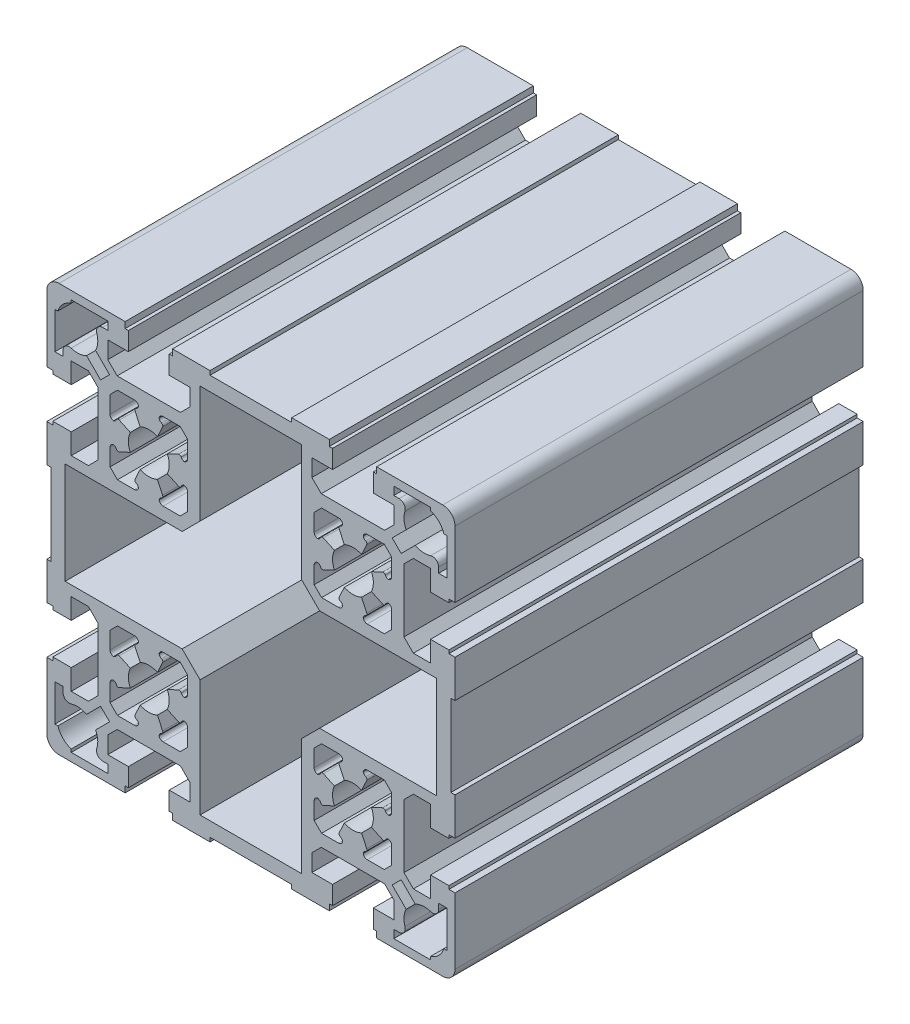
from build123d import *

# Parameters (mm, degrees)
BASE_EXTRUDE_DEPTH = 100


with BuildPart() as part:
    # Sketch1 → Base-Extrude (new body)
    with BuildSketch(Plane.XY):
        with BuildLine():
            Line((-17.25, -37.5), (-14.95, -39.8))
            Line((-14.95, -39.8), (-14.95, -44))
            Line((-14.95, -44), (-20, -44))
            Line((-20, -44), (-20, -48.5))
            Line((-20, -48.5), (-19.2, -48.5))
            Line((-19.2, -48.5), (-19.2, -50))
            Line((-19.2, -50), (-10, -50))
            Line((-10, -50), (-10, -49))
            Line((-10, -49), (10, -49))
            Line((10, -49), (10, -50))
            Line((10, -50), (19.2, -50))
            Line((19.2, -50), (19.2, -48.5))
            Line((19.2, -48.5), (20, -48.5))
            Line((20, -48.5), (20, -44))
            Line((20, -44), (14.95, -44))
            Line((14.95, -44), (14.95, -39.8))
            Line((14.95, -39.8), (17.25, -37.5))
            Line((17.25, -37.5), (32.75, -37.5))
            Line((32.75, -37.5), (35.05, -39.8))
            Line((35.05, -39.8), (35.05, -44))
            Line((35.05, -44), (30, -44))
            Line((30, -44), (30, -48.5))
            Line((30, -48.5), (30.8, -48.5))
            Line((30.8, -48.5), (30.8, -50))
            Line((30.8, -50), (47, -50))
            ThreePointArc((47, -50), (49.121320344, -49.121320344), (50, -47))
            Line((50, -47), (50, -30.8))
            Line((50, -30.8), (48.5, -30.8))
            Line((48.5, -30.8), (48.5, -30))
            Line((48.5, -30), (44, -30))
            Line((44, -30), (44, -35.05))
            Line((44, -35.05), (39.8, -35.05))
            Line((39.8, -35.05), (37.5, -32.75))
            Line((37.5, -32.75), (37.5, -17.25))
            Line((37.5, -17.25), (39.8, -14.95))
            Line((39.8, -14.95), (44, -14.95))
            Line((44, -14.95), (44, -20))
            Line((44, -20), (48.5, -20))
            Line((48.5, -20), (48.5, -19.2))
            Line((48.5, -19.2), (50, -19.2))
            Line((50, -19.2), (50, -10))
            Line((50, -10), (49, -10))
            Line((49, -10), (49, 10))
            Line((49, 10), (50, 10))
            Line((50, 10), (50, 19.2))
            Line((50, 19.2), (48.5, 19.2))
            Line((48.5, 19.2), (48.5, 20))
            Line((48.5, 20), (44, 20))
            Line((44, 20), (44, 14.95))
            Line((44, 14.95), (39.8, 14.95))
            Line((39.8, 14.95), (37.5, 17.25))
            Line((37.5, 17.25), (37.5, 32.75))
            Line((37.5, 32.75), (39.8, 35.05))
            Line((39.8, 35.05), (44, 35.05))
            Line((44, 35.05), (44, 30))
            Line((44, 30), (48.5, 30))
            Line((48.5, 30), (48.5, 30.8))
            Line((48.5, 30.8), (50, 30.8))
            Line((50, 30.8), (50, 47))
            ThreePointArc((50, 47), (49.121320344, 49.121320344), (47, 50))
            Line((47, 50), (30.8, 50))
            Line((30.8, 50), (30.8, 48.5))
            Line((30.8, 48.5), (30, 48.5))
            Line((30, 48.5), (30, 44))
            Line((30, 44), (35.05, 44))
            Line((35.05, 44), (35.05, 39.8))
            Line((35.05, 39.8), (32.75, 37.5))
            Line((32.75, 37.5), (17.25, 37.5))
            Line((17.25, 37.5), (14.95, 39.8))
            Line((14.95, 39.8), (14.95, 44))
            Line((14.95, 44), (20, 44))
            Line((20, 44), (20, 48.5))
            Line((20, 48.5), (19.2, 48.5))
            Line((19.2, 48.5), (19.2, 50))
            Line((19.2, 50), (10, 50))
            Line((10, 50), (10, 49))
            Line((10, 49), (-10, 49))
            Line((-10, 49), (-10, 50))
            Line((-10, 50), (-19.2, 50))
            Line((-19.2, 50), (-19.2, 48.5))
            Line((-19.2, 48.5), (-20, 48.5))
            Line((-20, 48.5), (-20, 44))
            Line((-20, 44), (-14.95, 44))
            Line((-14.95, 44), (-14.95, 39.8))
            Line((-14.95, 39.8), (-17.25, 37.5))
            Line((-17.25, 37.5), (-32.75, 37.5))
            Line((-32.75, 37.5), (-35.05, 39.8))
            Line((-35.05, 39.8), (-35.05, 44))
            Line((-35.05, 44), (-30, 44))
            Line((-30, 44), (-30, 48.5))
            Line((-30, 48.5), (-30.8, 48.5))
            Line((-30.8, 48.5), (-30.8, 50))
            Line((-30.8, 50), (-47, 50))
            ThreePointArc((-47, 50), (-49.121320344, 49.121320344), (-50, 47))
            Line((-50, 47), (-50, 30.8))
            Line((-50, 30.8), (-48.5, 30.8))
            Line((-48.5, 30.8), (-48.5, 30))
            Line((-48.5, 30), (-44, 30))
            Line((-44, 30), (-44, 35.05))
            Line((-44, 35.05), (-39.8, 35.05))
            Line((-39.8, 35.05), (-37.5, 32.75))
            Line((-37.5, 32.75), (-37.5, 17.25))
            Line((-37.5, 17.25), (-39.8, 14.95))
            Line((-39.8, 14.95), (-44, 14.95))
            Line((-44, 14.95), (-44, 20))
            Line((-44, 20), (-48.5, 20))
            Line((-48.5, 20), (-48.5, 19.2))
            Line((-48.5, 19.2), (-50, 19.2))
            Line((-50, 19.2), (-50, 10))
            Line((-50, 10), (-49, 10))
            Line((-49, 10), (-49, -10))
            Line((-49, -10), (-50, -10))
            Line((-50, -10), (-50, -19.2))
            Line((-50, -19.2), (-48.5, -19.2))
            Line((-48.5, -19.2), (-48.5, -20))
            Line((-48.5, -20), (-44, -20))
            Line((-44, -20), (-44, -14.95))
            Line((-44, -14.95), (-39.8, -14.95))
            Line((-39.8, -14.95), (-37.5, -17.25))
            Line((-37.5, -17.25), (-37.5, -32.75))
            Line((-37.5, -32.75), (-39.8, -35.05))
            Line((-39.8, -35.05), (-44, -35.05))
            Line((-44, -35.05), (-44, -30))
            Line((-44, -30), (-48.5, -30))
            Line((-48.5, -30), (-48.5, -30.8))
            Line((-48.5, -30.8), (-50, -30.8))
            Line((-50, -30.8), (-50, -47))
            ThreePointArc((-50, -47), (-49.121320344, -49.121320344), (-47, -50))
            Line((-47, -50), (-30.8, -50))
            Line((-30.8, -50), (-30.8, -48.5))
            Line((-30.8, -48.5), (-30, -48.5))
            Line((-30, -48.5), (-30, -44))
            Line((-30, -44), (-35.05, -44))
            Line((-35.05, -44), (-35.05, -39.8))
            Line((-35.05, -39.8), (-32.75, -37.5))
            Line((-32.75, -37.5), (-17.25, -37.5))
        make_face()
        with BuildLine():
            Line((-15.501428488, -32.680320318), (-17.320519374, -34.499411204))
            Line((-17.320519374, -34.499411204), (-21.501428488, -34.499411204))
            ThreePointArc((-21.501428488, -34.499411204), (-22.143687504, -34.265898879), (-22.485995728, -33.674417917))
            ThreePointArc((-22.485995728, -33.674417917), (-22.294361697, -33.240116066), (-21.92404675, -32.943116843))
            Line((-21.92404675, -32.943116843), (-21.862327157, -32.914336524))
            ThreePointArc((-21.862327157, -32.914336524), (-21.603789977, -32.632192702), (-21.620482394, -32.2498735))
            Line((-21.620482394, -32.2498735), (-22.888337179, -29.530950139))
            ThreePointArc((-22.888337179, -29.530950139), (-25.001428488, -29.999411204), (-27.114519797, -29.530950139))
            Line((-27.114519797, -29.530950139), (-28.382374582, -32.2498735))
            ThreePointArc((-28.382374582, -32.2498735), (-28.399066999, -32.632192702), (-28.140529819, -32.914336524))
            Line((-28.140529819, -32.914336524), (-28.078810226, -32.943116843))
            ThreePointArc((-28.078810226, -32.943116843), (-27.708495279, -33.240116066), (-27.516861248, -33.674417917))
            ThreePointArc((-27.516861248, -33.674417917), (-27.859169472, -34.265898879), (-28.501428488, -34.499411204))
            Line((-28.501428488, -34.499411204), (-32.682337602, -34.499411204))
            Line((-32.682337602, -34.499411204), (-34.501428488, -32.680320318))
            Line((-34.501428488, -32.680320318), (-34.501428488, -28.499411204))
            ThreePointArc((-34.501428488, -28.499411204), (-34.267916164, -27.857152188), (-33.676435201, -27.514843963))
            ThreePointArc((-33.676435201, -27.514843963), (-33.242133351, -27.706477994), (-32.945134128, -28.076792942))
            Line((-32.945134128, -28.076792942), (-32.916353809, -28.138512535))
            ThreePointArc((-32.916353809, -28.138512535), (-32.634209987, -28.397049714), (-32.251890784, -28.380357297))
            Line((-32.251890784, -28.380357297), (-29.532967423, -27.112502512))
            ThreePointArc((-29.532967423, -27.112502512), (-30.001428488, -24.999411204), (-29.532967423, -22.886319895))
            Line((-29.532967423, -22.886319895), (-32.251890784, -21.61846511))
            ThreePointArc((-32.251890784, -21.61846511), (-32.634209987, -21.601772693), (-32.916353809, -21.860309872))
            Line((-32.916353809, -21.860309872), (-32.94370564, -21.922618262))
            ThreePointArc((-32.94370564, -21.922618262), (-33.240704863, -22.292933209), (-33.675006713, -22.48456724))
            ThreePointArc((-33.675006713, -22.48456724), (-34.266487675, -22.142259016), (-34.5, -21.5))
            Line((-34.5, -21.5), (-34.5, -17.319090886))
            Line((-34.5, -17.319090886), (-32.680909114, -15.5))
            Line((-32.680909114, -15.5), (-28.5, -15.5))
            ThreePointArc((-28.5, -15.5), (-27.857740984, -15.733512325), (-27.51543276, -16.324993287))
            ThreePointArc((-27.51543276, -16.324993287), (-27.707066791, -16.759295137), (-28.077381738, -17.05629436))
            Line((-28.077381738, -17.05629436), (-28.139101331, -17.085074679))
            ThreePointArc((-28.139101331, -17.085074679), (-28.397638511, -17.367218501), (-28.380946094, -17.749537704))
            Line((-28.380946094, -17.749537704), (-27.113571921, -20.467430387))
            ThreePointArc((-27.113571921, -20.467430387), (-25.000905581, -19.999411231), (-22.888337179, -20.467872268))
            Line((-22.888337179, -20.467872268), (-21.620482394, -17.748948907))
            ThreePointArc((-21.620482394, -17.748948907), (-21.603789977, -17.366629705), (-21.862327157, -17.084485883))
            Line((-21.862327157, -17.084485883), (-21.92404675, -17.055705564))
            ThreePointArc((-21.92404675, -17.055705564), (-22.294361697, -16.758706341), (-22.485995728, -16.32440449))
            ThreePointArc((-22.485995728, -16.32440449), (-22.143687504, -15.732923528), (-21.501428488, -15.499411204))
            Line((-21.501428488, -15.499411204), (-17.320519374, -15.499411204))
            Line((-17.320519374, -15.499411204), (-15.501428488, -17.318502089))
            Line((-15.501428488, -17.318502089), (-15.501428488, -21.499411204))
            ThreePointArc((-15.501428488, -21.499411204), (-15.734940813, -22.141670219), (-16.326421775, -22.483978444))
            ThreePointArc((-16.326421775, -22.483978444), (-16.760723625, -22.292344413), (-17.057722849, -21.922029465))
            Line((-17.057722849, -21.922029465), (-17.086503167, -21.860309872))
            ThreePointArc((-17.086503167, -21.860309872), (-17.368646989, -21.601772693), (-17.750966192, -21.61846511))
            Line((-17.750966192, -21.61846511), (-20.469889553, -22.886319895))
            ThreePointArc((-20.469889553, -22.886319895), (-20.001428488, -24.999411204), (-20.469889553, -27.112502512))
            Line((-20.469889553, -27.112502512), (-17.750966192, -28.380357297))
            ThreePointArc((-17.750966192, -28.380357297), (-17.368646989, -28.397049714), (-17.086503167, -28.138512535))
            Line((-17.086503167, -28.138512535), (-17.057722849, -28.076792942))
            ThreePointArc((-17.057722849, -28.076792942), (-16.760723625, -27.706477994), (-16.326421775, -27.514843963))
            ThreePointArc((-16.326421775, -27.514843963), (-15.734940813, -27.857152188), (-15.501428488, -28.499411204))
            Line((-15.501428488, -28.499411204), (-15.501428488, -32.680320318))
        make_face(mode=Mode.SUBTRACT)
        Polygon((-12.45, -16.83355698), (-16.83355698, -12.45), (-45.5, -12.45), (-45.5, 12.45), (-16.83355698, 12.45), (-12.45, 16.83355698), (-12.45, 45.5), (12.45, 45.5), (12.45, 16.83355698), (16.83355698, 12.45), (45.5, 12.45), (45.5, -12.45), (16.83355698, -12.45), (12.45, -16.83355698), (12.45, -45.5), (-12.45, -45.5), align=None, mode=Mode.SUBTRACT)
        with BuildLine():
            Line((-48, -44), (-48, -35))
            Line((-48, -35), (-46, -35))
            Line((-46, -35), (-46, -36.315341562))
            ThreePointArc((-46, -36.315341562), (-45.382522608, -37.528252872), (-44.038461538, -37.742570432))
            ThreePointArc((-44.038461538, -37.742570432), (-42.111403126, -37.515123625), (-40.242871851, -38.038456263))
            Line((-40.242871851, -38.038456263), (-36.813982694, -34.609567107))
            Line((-36.813982694, -34.609567107), (-34.609567107, -36.813982694))
            Line((-34.609567107, -36.813982694), (-38.038456263, -40.242871851))
            ThreePointArc((-38.038456263, -40.242871851), (-37.515123625, -42.111403126), (-37.742570432, -44.038461538))
            ThreePointArc((-37.742570432, -44.038461538), (-37.528252872, -45.382522608), (-36.315341562, -46))
            Line((-36.315341562, -46), (-35, -46))
            Line((-35, -46), (-35, -48))
            Line((-35, -48), (-44, -48))
            Line((-44, -48), (-44, -47.269696007))
            ThreePointArc((-44, -47.269696007), (-46.035533906, -46.035533906), (-47.269696007, -44))
            Line((-47.269696007, -44), (-48, -44))
        make_face(mode=Mode.SUBTRACT)
        with BuildLine():
            Line((48, -35), (48, -44))
            Line((48, -44), (47.269696007, -44))
            ThreePointArc((47.269696007, -44), (46.035533906, -46.035533906), (44, -47.269696007))
            Line((44, -47.269696007), (44, -48))
            Line((44, -48), (35, -48))
            Line((35, -48), (35, -46))
            Line((35, -46), (36.315341562, -46))
            ThreePointArc((36.315341562, -46), (37.528252872, -45.382522608), (37.742570432, -44.038461538))
            ThreePointArc((37.742570432, -44.038461538), (37.515123625, -42.111403126), (38.038456263, -40.242871851))
            Line((38.038456263, -40.242871851), (34.609567107, -36.813982694))
            Line((34.609567107, -36.813982694), (36.813982694, -34.609567107))
            Line((36.813982694, -34.609567107), (40.242871851, -38.038456263))
            ThreePointArc((40.242871851, -38.038456263), (42.111403126, -37.515123625), (44.038461538, -37.742570432))
            ThreePointArc((44.038461538, -37.742570432), (45.382522608, -37.528252872), (46, -36.315341562))
            Line((46, -36.315341562), (46, -35))
            Line((46, -35), (48, -35))
        make_face(mode=Mode.SUBTRACT)
        with BuildLine():
            Line((34.5, -17.319090886), (34.5, -21.5))
            ThreePointArc((34.5, -21.5), (34.266487675, -22.142259016), (33.675006713, -22.48456724))
            ThreePointArc((33.675006713, -22.48456724), (33.240704863, -22.292933209), (32.94370564, -21.922618262))
            Line((32.94370564, -21.922618262), (32.914925321, -21.860898669))
            ThreePointArc((32.914925321, -21.860898669), (32.632781499, -21.602361489), (32.250462296, -21.619053906))
            Line((32.250462296, -21.619053906), (29.531538935, -22.886908691))
            ThreePointArc((29.531538935, -22.886908691), (30, -25), (29.531538935, -27.113091309))
            Line((29.531538935, -27.113091309), (32.250462296, -28.380946094))
            ThreePointArc((32.250462296, -28.380946094), (32.632781499, -28.397638511), (32.914925321, -28.139101331))
            Line((32.914925321, -28.139101331), (32.94370564, -28.077381738))
            ThreePointArc((32.94370564, -28.077381738), (33.240704863, -27.707066791), (33.675006713, -27.51543276))
            ThreePointArc((33.675006713, -27.51543276), (34.266487675, -27.857740984), (34.5, -28.5))
            Line((34.5, -28.5), (34.5, -32.680909114))
            Line((34.5, -32.680909114), (32.680909114, -34.5))
            Line((32.680909114, -34.5), (28.5, -34.5))
            ThreePointArc((28.5, -34.5), (27.857740984, -34.266487675), (27.51543276, -33.675006713))
            ThreePointArc((27.51543276, -33.675006713), (27.707066791, -33.240704863), (28.077381738, -32.94370564))
            Line((28.077381738, -32.94370564), (28.139101331, -32.914925321))
            ThreePointArc((28.139101331, -32.914925321), (28.397638511, -32.632781499), (28.380946094, -32.250462296))
            Line((28.380946094, -32.250462296), (27.113091309, -29.531538935))
            ThreePointArc((27.113091309, -29.531538935), (25, -30), (22.886908691, -29.531538935))
            Line((22.886908691, -29.531538935), (21.619053906, -32.250462296))
            ThreePointArc((21.619053906, -32.250462296), (21.602361489, -32.632781499), (21.860898669, -32.914925321))
            Line((21.860898669, -32.914925321), (21.922618262, -32.94370564))
            ThreePointArc((21.922618262, -32.94370564), (22.292933209, -33.240704863), (22.48456724, -33.675006713))
            ThreePointArc((22.48456724, -33.675006713), (22.142259016, -34.266487675), (21.5, -34.5))
            Line((21.5, -34.5), (17.319090886, -34.5))
            Line((17.319090886, -34.5), (15.5, -32.680909114))
            Line((15.5, -32.680909114), (15.5, -28.5))
            ThreePointArc((15.5, -28.5), (15.733512325, -27.857740984), (16.324993287, -27.51543276))
            ThreePointArc((16.324993287, -27.51543276), (16.759295137, -27.707066791), (17.05629436, -28.077381738))
            Line((17.05629436, -28.077381738), (17.085074679, -28.139101331))
            ThreePointArc((17.085074679, -28.139101331), (17.367218501, -28.397638511), (17.749537704, -28.380946094))
            Line((17.749537704, -28.380946094), (20.468461065, -27.113091309))
            ThreePointArc((20.468461065, -27.113091309), (20, -25), (20.468461065, -22.886908691))
            Line((20.468461065, -22.886908691), (17.749537704, -21.619053906))
            ThreePointArc((17.749537704, -21.619053906), (17.367218501, -21.602361489), (17.085074679, -21.860898669))
            Line((17.085074679, -21.860898669), (17.05629436, -21.922618262))
            ThreePointArc((17.05629436, -21.922618262), (16.759295137, -22.292933209), (16.324993287, -22.48456724))
            ThreePointArc((16.324993287, -22.48456724), (15.733512325, -22.142259016), (15.5, -21.5))
            Line((15.5, -21.5), (15.5, -17.319090886))
            Line((15.5, -17.319090886), (17.319090886, -15.5))
            Line((17.319090886, -15.5), (21.5, -15.5))
            ThreePointArc((21.5, -15.5), (22.142259016, -15.733512325), (22.48456724, -16.324993287))
            ThreePointArc((22.48456724, -16.324993287), (22.292933209, -16.759295137), (21.922618262, -17.05629436))
            Line((21.922618262, -17.05629436), (21.860898669, -17.085074679))
            ThreePointArc((21.860898669, -17.085074679), (21.602361489, -17.367218501), (21.619053906, -17.749537704))
            Line((21.619053906, -17.749537704), (22.886908691, -20.468461065))
            ThreePointArc((22.886908691, -20.468461065), (25, -20), (27.113091309, -20.468461065))
            Line((27.113091309, -20.468461065), (28.380946094, -17.749537704))
            ThreePointArc((28.380946094, -17.749537704), (28.397638511, -17.367218501), (28.139101331, -17.085074679))
            Line((28.139101331, -17.085074679), (28.077381738, -17.05629436))
            ThreePointArc((28.077381738, -17.05629436), (27.707066791, -16.759295137), (27.51543276, -16.324993287))
            ThreePointArc((27.51543276, -16.324993287), (27.857740984, -15.733512325), (28.5, -15.5))
            Line((28.5, -15.5), (32.680909114, -15.5))
            Line((32.680909114, -15.5), (34.5, -17.319090886))
        make_face(mode=Mode.SUBTRACT)
        with BuildLine():
            Line((-17.319090886, 34.5), (-15.5, 32.680909114))
            Line((-15.5, 32.680909114), (-15.5, 28.5))
            ThreePointArc((-15.5, 28.5), (-15.733512325, 27.857740984), (-16.324993287, 27.51543276))
            ThreePointArc((-16.324993287, 27.51543276), (-16.759295137, 27.707066791), (-17.05629436, 28.077381738))
            Line((-17.05629436, 28.077381738), (-17.085074679, 28.139101331))
            ThreePointArc((-17.085074679, 28.139101331), (-17.367218501, 28.397638511), (-17.749537704, 28.380946094))
            Line((-17.749537704, 28.380946094), (-20.468461065, 27.113091309))
            ThreePointArc((-20.468461065, 27.113091309), (-20, 25), (-20.468461065, 22.886908691))
            Line((-20.468461065, 22.886908691), (-17.749537704, 21.619053906))
            ThreePointArc((-17.749537704, 21.619053906), (-17.367218501, 21.602361489), (-17.085074679, 21.860898669))
            Line((-17.085074679, 21.860898669), (-17.05629436, 21.922618262))
            ThreePointArc((-17.05629436, 21.922618262), (-16.759295137, 22.292933209), (-16.324993287, 22.48456724))
            ThreePointArc((-16.324993287, 22.48456724), (-15.733512325, 22.142259016), (-15.5, 21.5))
            Line((-15.5, 21.5), (-15.5, 17.319090886))
            Line((-15.5, 17.319090886), (-17.319090886, 15.5))
            Line((-17.319090886, 15.5), (-21.5, 15.5))
            ThreePointArc((-21.5, 15.5), (-22.142259016, 15.733512325), (-22.48456724, 16.324993287))
            ThreePointArc((-22.48456724, 16.324993287), (-22.292933209, 16.759295137), (-21.922618262, 17.05629436))
            Line((-21.922618262, 17.05629436), (-21.860898669, 17.085074679))
            ThreePointArc((-21.860898669, 17.085074679), (-21.602361489, 17.367218501), (-21.619053906, 17.749537704))
            Line((-21.619053906, 17.749537704), (-22.886908691, 20.468461065))
            ThreePointArc((-22.886908691, 20.468461065), (-25, 20), (-27.113091309, 20.468461065))
            Line((-27.113091309, 20.468461065), (-28.380946094, 17.749537704))
            ThreePointArc((-28.380946094, 17.749537704), (-28.397638511, 17.367218501), (-28.139101331, 17.085074679))
            Line((-28.139101331, 17.085074679), (-28.077381738, 17.05629436))
            ThreePointArc((-28.077381738, 17.05629436), (-27.707066791, 16.759295137), (-27.51543276, 16.324993287))
            ThreePointArc((-27.51543276, 16.324993287), (-27.857740984, 15.733512325), (-28.5, 15.5))
            Line((-28.5, 15.5), (-32.680909114, 15.5))
            Line((-32.680909114, 15.5), (-34.5, 17.319090886))
            Line((-34.5, 17.319090886), (-34.5, 21.5))
            ThreePointArc((-34.5, 21.5), (-34.266487675, 22.142259016), (-33.675006713, 22.48456724))
            ThreePointArc((-33.675006713, 22.48456724), (-33.240704863, 22.292933209), (-32.94370564, 21.922618262))
            Line((-32.94370564, 21.922618262), (-32.914925321, 21.860898669))
            ThreePointArc((-32.914925321, 21.860898669), (-32.632781499, 21.602361489), (-32.250462296, 21.619053906))
            Line((-32.250462296, 21.619053906), (-29.531538935, 22.886908691))
            ThreePointArc((-29.531538935, 22.886908691), (-30, 25), (-29.531538935, 27.113091309))
            Line((-29.531538935, 27.113091309), (-32.250462296, 28.380946094))
            ThreePointArc((-32.250462296, 28.380946094), (-32.632781499, 28.397638511), (-32.914925321, 28.139101331))
            Line((-32.914925321, 28.139101331), (-32.94370564, 28.077381738))
            ThreePointArc((-32.94370564, 28.077381738), (-33.240704863, 27.707066791), (-33.675006713, 27.51543276))
            ThreePointArc((-33.675006713, 27.51543276), (-34.266487675, 27.857740984), (-34.5, 28.5))
            Line((-34.5, 28.5), (-34.5, 32.680909114))
            Line((-34.5, 32.680909114), (-32.680909114, 34.5))
            Line((-32.680909114, 34.5), (-28.5, 34.5))
            ThreePointArc((-28.5, 34.5), (-27.857740984, 34.266487675), (-27.51543276, 33.675006713))
            ThreePointArc((-27.51543276, 33.675006713), (-27.707066791, 33.240704863), (-28.077381738, 32.94370564))
            Line((-28.077381738, 32.94370564), (-28.139690128, 32.916353809))
            ThreePointArc((-28.139690128, 32.916353809), (-28.398227307, 32.634209987), (-28.38153489, 32.251890784))
            Line((-28.38153489, 32.251890784), (-27.1130278, 29.531568549))
            ThreePointArc((-27.1130278, 29.531568549), (-24.999964963, 30), (-22.886908691, 29.531538935))
            Line((-22.886908691, 29.531538935), (-21.619053906, 32.250462296))
            ThreePointArc((-21.619053906, 32.250462296), (-21.602361489, 32.632781499), (-21.860898669, 32.914925321))
            Line((-21.860898669, 32.914925321), (-21.922618262, 32.94370564))
            ThreePointArc((-21.922618262, 32.94370564), (-22.292933209, 33.240704863), (-22.48456724, 33.675006713))
            ThreePointArc((-22.48456724, 33.675006713), (-22.142259016, 34.266487675), (-21.5, 34.5))
            Line((-21.5, 34.5), (-17.319090886, 34.5))
        make_face(mode=Mode.SUBTRACT)
        with BuildLine():
            Line((-48, 35), (-48, 44))
            Line((-48, 44), (-47.269696007, 44))
            ThreePointArc((-47.269696007, 44), (-46.035533906, 46.035533906), (-44, 47.269696007))
            Line((-44, 47.269696007), (-44, 48))
            Line((-44, 48), (-35, 48))
            Line((-35, 48), (-35, 46))
            Line((-35, 46), (-36.315341562, 46))
            ThreePointArc((-36.315341562, 46), (-37.528252872, 45.382522608), (-37.742570432, 44.038461538))
            ThreePointArc((-37.742570432, 44.038461538), (-37.515123625, 42.111403126), (-38.038456263, 40.242871851))
            Line((-38.038456263, 40.242871851), (-34.609567107, 36.813982694))
            Line((-34.609567107, 36.813982694), (-36.813982694, 34.609567107))
            Line((-36.813982694, 34.609567107), (-40.242871851, 38.038456263))
            ThreePointArc((-40.242871851, 38.038456263), (-42.111403126, 37.515123625), (-44.038461538, 37.742570432))
            ThreePointArc((-44.038461538, 37.742570432), (-45.382522608, 37.528252872), (-46, 36.315341562))
            Line((-46, 36.315341562), (-46, 35))
            Line((-46, 35), (-48, 35))
        make_face(mode=Mode.SUBTRACT)
        with BuildLine():
            Line((28.380946094, 17.749537704), (27.113091309, 20.468461065))
            ThreePointArc((27.113091309, 20.468461065), (25, 20), (22.886908691, 20.468461065))
            Line((22.886908691, 20.468461065), (21.619053906, 17.749537704))
            ThreePointArc((21.619053906, 17.749537704), (21.602361489, 17.367218501), (21.860898669, 17.085074679))
            Line((21.860898669, 17.085074679), (21.922618262, 17.05629436))
            ThreePointArc((21.922618262, 17.05629436), (22.292933209, 16.759295137), (22.48456724, 16.324993287))
            ThreePointArc((22.48456724, 16.324993287), (22.142259016, 15.733512325), (21.5, 15.5))
            Line((21.5, 15.5), (17.319090886, 15.5))
            Line((17.319090886, 15.5), (15.5, 17.319090886))
            Line((15.5, 17.319090886), (15.5, 21.5))
            ThreePointArc((15.5, 21.5), (15.733512325, 22.142259016), (16.324993287, 22.48456724))
            ThreePointArc((16.324993287, 22.48456724), (16.759295137, 22.292933209), (17.05629436, 21.922618262))
            Line((17.05629436, 21.922618262), (17.085074679, 21.860898669))
            ThreePointArc((17.085074679, 21.860898669), (17.367218501, 21.602361489), (17.749537704, 21.619053906))
            Line((17.749537704, 21.619053906), (20.468461065, 22.886908691))
            ThreePointArc((20.468461065, 22.886908691), (20, 25), (20.468461065, 27.113091309))
            Line((20.468461065, 27.113091309), (17.749537704, 28.380946094))
            ThreePointArc((17.749537704, 28.380946094), (17.367218501, 28.397638511), (17.085074679, 28.139101331))
            Line((17.085074679, 28.139101331), (17.05629436, 28.077381738))
            ThreePointArc((17.05629436, 28.077381738), (16.759295137, 27.707066791), (16.324993287, 27.51543276))
            ThreePointArc((16.324993287, 27.51543276), (15.733512325, 27.857740984), (15.5, 28.5))
            Line((15.5, 28.5), (15.5, 32.680909114))
            Line((15.5, 32.680909114), (17.319090886, 34.5))
            Line((17.319090886, 34.5), (21.5, 34.5))
            ThreePointArc((21.5, 34.5), (22.142259016, 34.266487675), (22.48456724, 33.675006713))
            ThreePointArc((22.48456724, 33.675006713), (22.292933209, 33.240704863), (21.922618262, 32.94370564))
            Line((21.922618262, 32.94370564), (21.860309872, 32.916353809))
            ThreePointArc((21.860309872, 32.916353809), (21.601772693, 32.634209987), (21.61846511, 32.251890784))
            Line((21.61846511, 32.251890784), (22.8869722, 29.531568549))
            ThreePointArc((22.8869722, 29.531568549), (25.000035037, 30), (27.113091309, 29.531538935))
            Line((27.113091309, 29.531538935), (28.380946094, 32.250462296))
            ThreePointArc((28.380946094, 32.250462296), (28.397638511, 32.632781499), (28.139101331, 32.914925321))
            Line((28.139101331, 32.914925321), (28.076792942, 32.942277151))
            ThreePointArc((28.076792942, 32.942277151), (27.706477994, 33.239276375), (27.514843963, 33.673578225))
            ThreePointArc((27.514843963, 33.673578225), (27.857152188, 34.265059187), (28.499411203, 34.498571512))
            Line((28.499411203, 34.498571512), (32.680320318, 34.498571512))
            Line((32.680320318, 34.498571512), (34.499411203, 32.679480626))
            Line((34.499411203, 32.679480626), (34.499411203, 28.498571512))
            ThreePointArc((34.499411203, 28.498571512), (34.265898879, 27.856312496), (33.674417917, 27.514004272))
            ThreePointArc((33.674417917, 27.514004272), (33.240116066, 27.705638303), (32.943116843, 28.07595325))
            Line((32.943116843, 28.07595325), (32.914336524, 28.137672843))
            ThreePointArc((32.914336524, 28.137672843), (32.632192702, 28.396210023), (32.2498735, 28.379517606))
            Line((32.2498735, 28.379517606), (29.531980816, 27.112143433))
            ThreePointArc((29.531980816, 27.112143433), (29.999999973, 24.999477093), (29.531538935, 22.886908691))
            Line((29.531538935, 22.886908691), (32.250462296, 21.619053906))
            ThreePointArc((32.250462296, 21.619053906), (32.632781499, 21.602361489), (32.914925321, 21.860898669))
            Line((32.914925321, 21.860898669), (32.94370564, 21.922618262))
            ThreePointArc((32.94370564, 21.922618262), (33.240704863, 22.292933209), (33.675006713, 22.48456724))
            ThreePointArc((33.675006713, 22.48456724), (34.266487675, 22.142259016), (34.5, 21.5))
            Line((34.5, 21.5), (34.5, 17.319090886))
            Line((34.5, 17.319090886), (32.680909114, 15.5))
            Line((32.680909114, 15.5), (28.5, 15.5))
            ThreePointArc((28.5, 15.5), (27.857740984, 15.733512325), (27.51543276, 16.324993287))
            ThreePointArc((27.51543276, 16.324993287), (27.707066791, 16.759295137), (28.077381738, 17.05629436))
            Line((28.077381738, 17.05629436), (28.139101331, 17.085074679))
            ThreePointArc((28.139101331, 17.085074679), (28.397638511, 17.367218501), (28.380946094, 17.749537704))
        make_face(mode=Mode.SUBTRACT)
        with BuildLine():
            Line((48, 44), (48, 35))
            Line((48, 35), (46, 35))
            Line((46, 35), (46, 36.315341562))
            ThreePointArc((46, 36.315341562), (45.382522608, 37.528252872), (44.038461538, 37.742570432))
            ThreePointArc((44.038461538, 37.742570432), (42.111403126, 37.515123625), (40.242871851, 38.038456263))
            Line((40.242871851, 38.038456263), (36.813982694, 34.609567107))
            Line((36.813982694, 34.609567107), (34.609567107, 36.813982694))
            Line((34.609567107, 36.813982694), (38.038456263, 40.242871851))
            ThreePointArc((38.038456263, 40.242871851), (37.515123625, 42.111403126), (37.742570432, 44.038461538))
            ThreePointArc((37.742570432, 44.038461538), (37.528252872, 45.382522608), (36.315341562, 46))
            Line((36.315341562, 46), (35, 46))
            Line((35, 46), (35, 48))
            Line((35, 48), (44, 48))
            Line((44, 48), (44, 47.269696007))
            ThreePointArc((44, 47.269696007), (46.035533906, 46.035533906), (47.269696007, 44))
            Line((47.269696007, 44), (48, 44))
        make_face(mode=Mode.SUBTRACT)
    extrude(amount=-BASE_EXTRUDE_DEPTH)


solid = part.part
